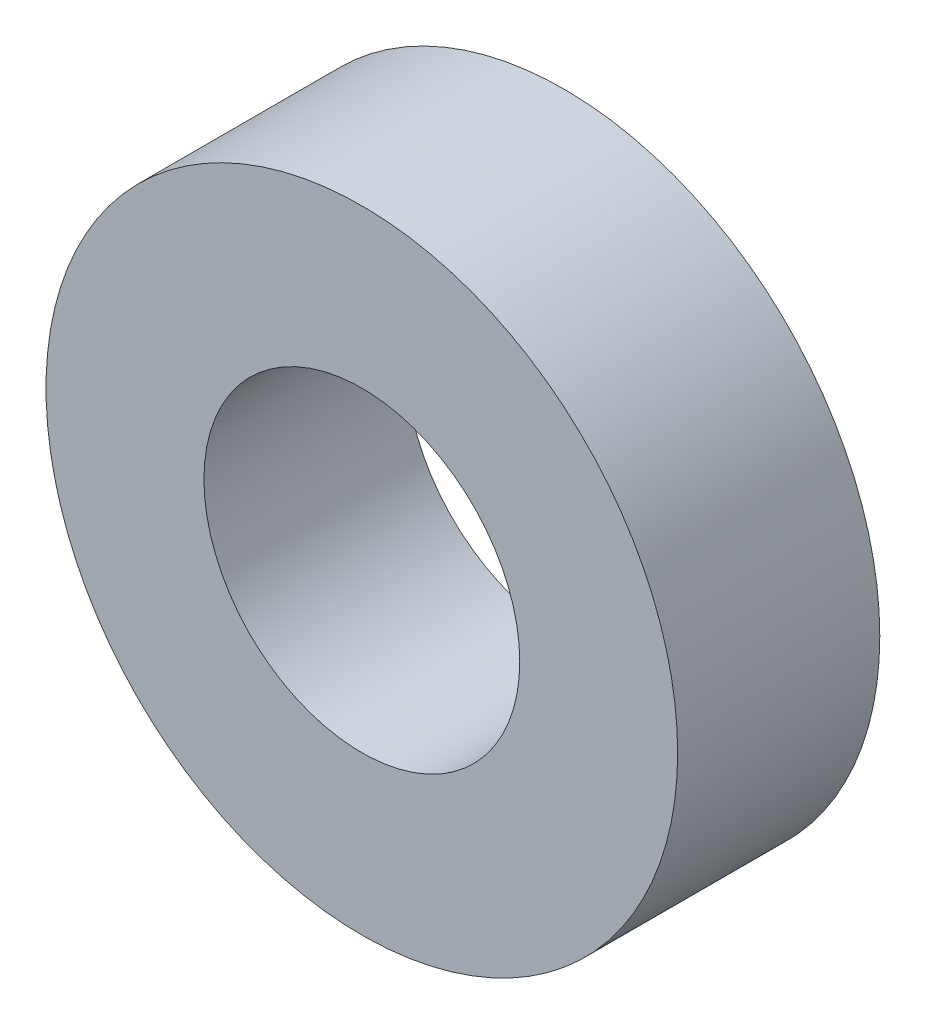
from build123d import *

# Parameters (mm, degrees)
ESQUISSE1_R        = 12.5
ESQUISSE1_R_2      = 6.25
BOSS_EXTRU_1_DEPTH = 8


with BuildPart() as part:
    # Esquisse1 → Boss.-Extru.1 (new body)
    with BuildSketch(Plane.XY):
        Circle(ESQUISSE1_R)
        Circle(ESQUISSE1_R_2, mode=Mode.SUBTRACT)
    extrude(amount=BOSS_EXTRU_1_DEPTH)


solid = part.part
